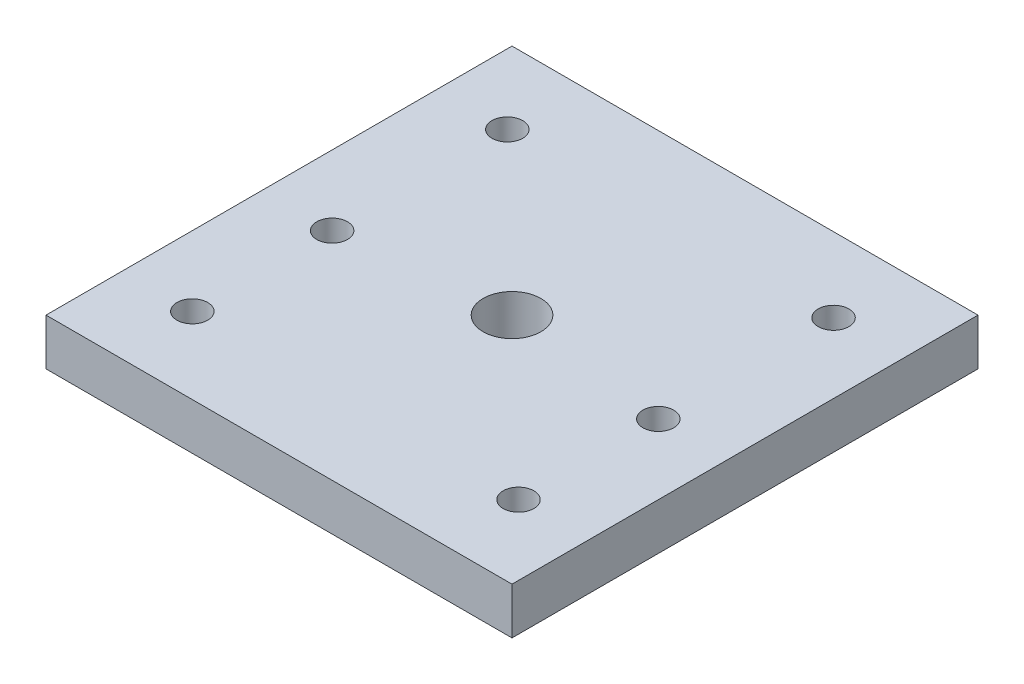
from build123d import *

# Parameters (mm, degrees)
SKETCH2_W              = 127
SKETCH2_H              = 127
BOSS_EXTRUDE1_DEPTH    = 12.7
F_10_0MM_DOWEL_HOLE1_D = 8.382
SKETCH12_R             = 7.874
CUT_EXTRUDE2_DEPTH     = 13.7


with BuildPart() as part:
    # Sketch2 → Boss-Extrude1 (new body)
    with BuildSketch(Plane(origin=(0, 0, 0), x_dir=(1, 0, 0), z_dir=(0, 1, 0))):
        Rectangle(SKETCH2_W, SKETCH2_H)
    extrude(amount=BOSS_EXTRUDE1_DEPTH)

    # Ø10.0mm Dowel Hole1 (through all)
    with Locations(Plane(origin=(0, 0, 0), x_dir=(-1, 0, 0), z_dir=(0, -1, 0))):
        with Locations((-44.45, 43.18), (-44.45, -4.572), (-44.45, -42.672), (44.45, 43.18), (44.45, -4.572), (44.45, -42.672)):
            Hole(F_10_0MM_DOWEL_HOLE1_D / 2)

    # Sketch12 → Cut-Extrude2 (cut, through all)
    with BuildSketch(Plane.XZ):
        Circle(SKETCH12_R)
    extrude(amount=-CUT_EXTRUDE2_DEPTH, mode=Mode.SUBTRACT)


solid = part.part
